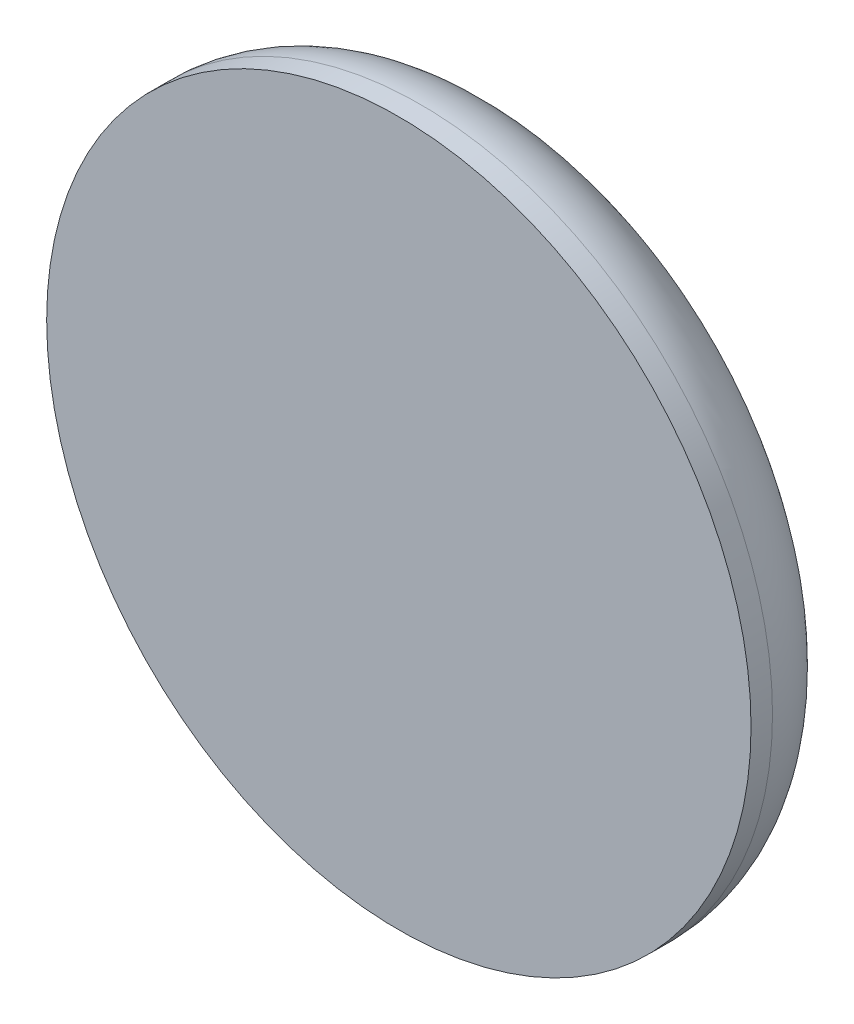
from build123d import *


with BuildPart() as part:
    # Croquis1 → Revolución1 (revolve)
    with BuildSketch(Plane(origin=(0, 0, 0), x_dir=(1, 0, 0), z_dir=(0, 1, 0))):
        with BuildLine():
            Line((0, 0), (0.625, 0))
            Line((0.625, 0), (0.625, 0.038088908))
            ThreePointArc((0.625, 0.038088908), (0.593884997, 0.129556703), (0.513448567, 0.183077555))
            ThreePointArc((0.513448567, 0.183077555), (0.258895753, 0.23319893), (0, 0.25))
            Line((0, 0.25), (0, 0))
        make_face()
    revolve(axis=Axis((0, 0, 0), (0, 0, -1)))


solid = part.part
